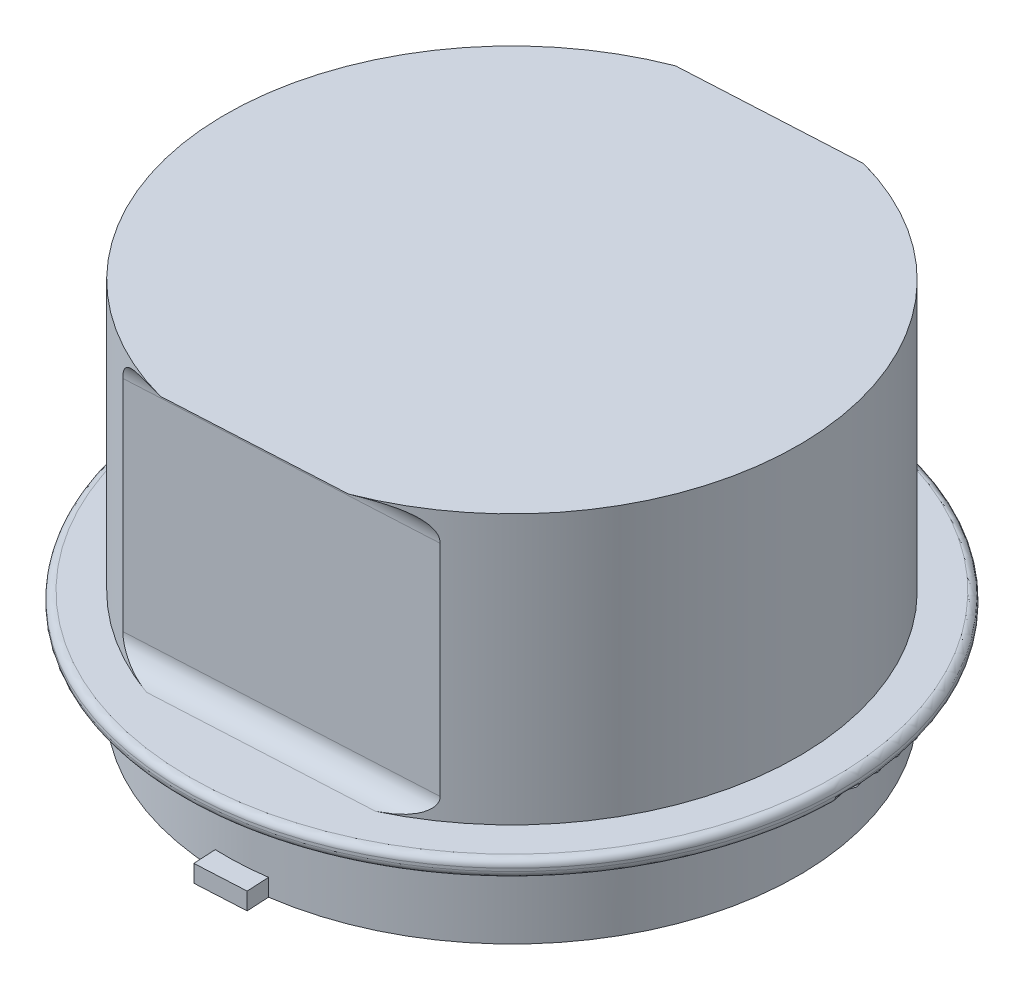
from build123d import *

# Parameters (mm, degrees)
CUT_EXTRUDE1_DEPTH       = 57.404
SKETCH5_W                = 4.4958
SKETCH5_H                = 1.524
BOSS_EXTRUDE1_DEPTH      = 1.905
BOSS_EXTRUDE1_DEPTH_BACK = 52.705


with BuildPart() as part:
    # Sketch1 → Revolve2 (revolve)
    with BuildSketch(Plane.XY):
        with BuildLine():
            Line((0, 25.4), (0, 1.524))
            Line((0, 1.524), (-3.175, 1.524))
            ThreePointArc((-3.175, 1.524), (-3.624012806, 1.338012806), (-3.81, 0.889))
            Line((-3.81, 0.889), (-3.81, 0.635))
            ThreePointArc((-3.81, 0.635), (-3.624012806, 0.185987194), (-3.175, 0))
            Line((-3.175, 0), (0, 0))
            Line((0, 0), (0, -7.62))
            Line((0, -7.62), (25.4, -7.62))
            Line((25.4, -7.62), (25.4, 25.4))
            Line((25.4, 25.4), (0, 25.4))
        make_face()
    revolve(axis=Axis((25.4, -7.62, 0), (0, 1, 0)))

    # Sketch4 → Cut-Extrude1 (cut)
    with BuildSketch(Plane(origin=(0.035154624, -7.62, 1.335896343), x_dir=(0.052594344, 0, 0.99861596), z_dir=(-0.99861596, 0, 0.052594344))):
        with BuildLine():
            Line((-23.495, 9.144), (-26.67, 9.144))
            Line((-26.67, 9.144), (-26.67, 33.02))
            Line((-26.67, 33.02), (-24.13, 33.02))
            ThreePointArc((-24.13, 33.02), (-22.333948776, 32.276051224), (-21.59, 30.48))
            Line((-21.59, 30.48), (-21.59, 11.049))
            ThreePointArc((-21.59, 11.049), (-22.147961582, 9.701961582), (-23.495, 9.144))
        make_face()
        with BuildLine():
            Line((21.59, 30.48), (21.59, 11.049))
            ThreePointArc((21.59, 11.049), (22.147961582, 9.701961582), (23.495, 9.144))
            Line((23.495, 9.144), (26.67, 9.144))
            Line((26.67, 9.144), (26.67, 33.02))
            Line((26.67, 33.02), (24.13, 33.02))
            ThreePointArc((24.13, 33.02), (22.333948776, 32.276051224), (21.59, 30.48))
        make_face()
    extrude(amount=-CUT_EXTRUDE1_DEPTH, mode=Mode.SUBTRACT)

    # Sketch5 → Boss-Extrude1 (add, two sides)
    with BuildSketch(Plane(origin=(26.735896343, 0, 25.364845376), x_dir=(0.99861596, 0, -0.052594344), z_dir=(0.052594344, 0, 0.99861596))) as boss_extrude1_sk:
        with Locations((0, -6.858)):
            Rectangle(SKETCH5_W, SKETCH5_H)
    extrude(amount=BOSS_EXTRUDE1_DEPTH)
    extrude(boss_extrude1_sk.sketch, amount=-BOSS_EXTRUDE1_DEPTH_BACK)


solid = part.part
